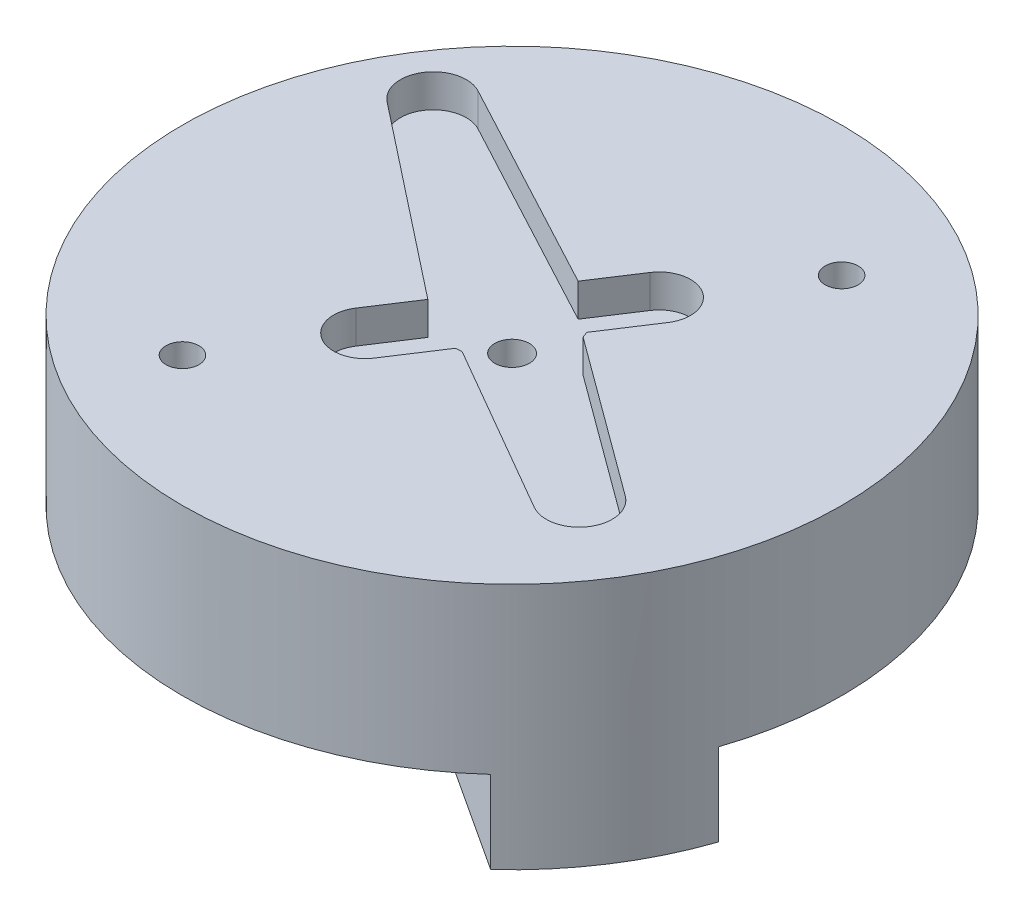
from build123d import *

# Parameters (mm, degrees)
SKETCH1_R           = 20
SKETCH1_R_2         = 1
BOSS_EXTRUDE1_DEPTH = 2
SKETCH2_R           = 20
SKETCH2_R_2         = 1
SKETCH2_R_3         = 2.3
BOSS_EXTRUDE3_DEPTH = 8
BOSS_EXTRUDE4_DEPTH = 5
SKETCH4_R           = 2.3
SKETCH4_R_2         = 1.05
BOSS_EXTRUDE5_DEPTH = 2
SKETCH5_R           = 0.740059644
CUT_EXTRUDE1_DEPTH  = 6


with BuildPart() as part:
    # Sketch1 → Boss-Extrude1 (new body)
    with BuildSketch(Plane(origin=(0, 0, 0), x_dir=(1, 0, 0), z_dir=(0, 1, 0))):
        with Locations((-25.651058935, -9.088114724)):
            Circle(SKETCH1_R)
        with Locations((-17.747716132, 3.008978834)):
            Circle(SKETCH1_R_2, mode=Mode.SUBTRACT)
        with Locations((-33.554401738, -21.185208281)):
            Circle(SKETCH1_R_2, mode=Mode.SUBTRACT)
        with BuildLine():
            ThreePointArc((-20.532647943, -4.727567864), (-21.084075378, -2.097752703), (-23.713890539, -2.649180137))
            Line((-23.713890539, -2.649180137), (-25.439308031, -5.290155905))
            Line((-25.439308031, -5.290155905), (-38.480446345, 1.673359092))
            ThreePointArc((-38.480446345, 1.673359092), (-41.09682891, 1.003004634), (-40.659707143, -1.662282853))
            Line((-40.659707143, -1.662282853), (-29.044052435, -10.807685815))
            Line((-29.044052435, -10.807685815), (-30.769469927, -13.448661583))
            ThreePointArc((-30.769469927, -13.448661583), (-30.218042492, -16.078476745), (-27.588227331, -15.52704931))
            Line((-27.588227331, -15.52704931), (-25.63545633, -12.538079442))
            Line((-25.63545633, -12.538079442), (-25.251093904, -12.514851944))
            Line((-25.251093904, -12.514851944), (-14.889738345, -18.504207673))
            ThreePointArc((-14.889738345, -18.504207673), (-12.21449481, -17.866568148), (-12.705220614, -15.16051931))
            Line((-12.705220614, -15.16051931), (-22.35228997, -8.077855691))
            Line((-22.35228997, -8.077855691), (-22.485418943, -7.716537732))
            Line((-22.485418943, -7.716537732), (-20.532647943, -4.727567864))
        make_face(mode=Mode.SUBTRACT)
    extrude(amount=BOSS_EXTRUDE1_DEPTH)

    # Sketch2 → Boss-Extrude3 (add)
    with BuildSketch(Plane.XZ):
        with Locations((-25.651058935, 9.088114724)):
            Circle(SKETCH2_R)
        with Locations((-17.747716132, -3.008978834)):
            Circle(SKETCH2_R_2, mode=Mode.SUBTRACT)
        with Locations((-33.554401738, 21.185208281)):
            Circle(SKETCH2_R_2, mode=Mode.SUBTRACT)
        with Locations((-25.651058935, 9.088114724)):
            Circle(SKETCH2_R_3, mode=Mode.SUBTRACT)
    extrude(amount=BOSS_EXTRUDE3_DEPTH)

    # Sketch3 → Boss-Extrude4 (add)
    with BuildSketch(Plane.XZ.offset(8)):
        with BuildLine():
            Line((-23.725569995, 10.346086242), (-26.460290688, 14.531931764))
            Line((-26.460290688, 14.531931764), (-12.174069633, 23.865487946))
            ThreePointArc((-12.174069633, 23.865487946), (-8.907676848, 20.026997496), (-6.704628247, 15.493796903))
            Line((-6.704628247, 15.493796903), (-20.990849302, 6.160240721))
            Line((-20.990849302, 6.160240721), (-23.725569995, 10.346086242))
        make_face()
        with BuildLine():
            Line((-27.576547875, 7.830143205), (-24.841827182, 3.644297683))
            Line((-24.841827182, 3.644297683), (-39.128048237, -5.689258499))
            ThreePointArc((-39.128048237, -5.689258499), (-42.394441021, -1.850768048), (-44.597489623, 2.682432545))
            Line((-44.597489623, 2.682432545), (-30.311268568, 12.015988727))
            Line((-30.311268568, 12.015988727), (-27.576547875, 7.830143205))
        make_face()
    extrude(amount=BOSS_EXTRUDE4_DEPTH)

    # Sketch4 → Boss-Extrude5 (add)
    with BuildSketch(Plane(origin=(0, 0, 0), x_dir=(1, 0, 0), z_dir=(0, 1, 0))):
        with Locations((-25.651058935, -9.088114724)):
            Circle(SKETCH4_R)
        with Locations((-25.651058935, -9.088114724)):
            Circle(SKETCH4_R_2, mode=Mode.SUBTRACT)
    extrude(amount=-BOSS_EXTRUDE5_DEPTH)

    # Sketch5 → Cut-Extrude1 (cut)
    with BuildSketch(Plane(origin=(0, 2, 0), x_dir=(1, 0, 0), z_dir=(0, 1, 0))):
        with Locations((-20.12753999, 54.77317824)):
            Circle(SKETCH5_R)
    extrude(amount=-CUT_EXTRUDE1_DEPTH, mode=Mode.SUBTRACT)


solid = part.part
